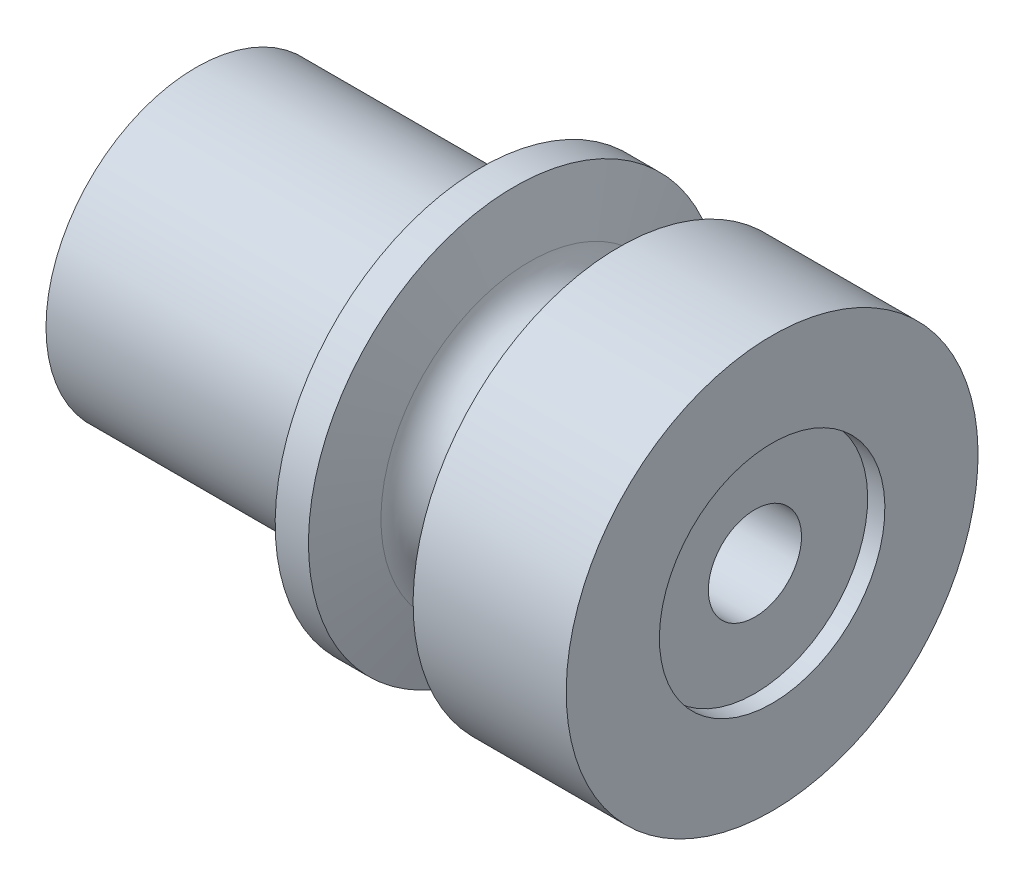
from build123d import *


with BuildPart() as part:
    # Sketch1 → Revolve1 (revolve)
    with BuildSketch(Plane.XY):
        with BuildLine():
            Line((-7.83533025, 7.706480957), (-7.041793614, 10.668))
            Line((-7.041793614, 10.668), (0.892, 10.668))
            Line((0.892, 10.668), (0.892, 5.842))
            Line((0.892, 5.842), (0, 5.842))
            Line((0, 5.842), (0, 2.413))
            Line((0, 2.413), (-24.6126, 2.413))
            Line((-24.6126, 2.413), (-28.956, 6.7564))
            Line((-28.956, 6.7564), (-28.956, 7.7724))
            Line((-28.956, 7.7724), (-14.188119198, 7.7724))
            Line((-14.188119198, 7.7724), (-14.188119198, 10.668))
            Line((-14.188119198, 10.668), (-12.462385009, 10.668))
            Line((-12.462385009, 10.668), (-11.668848373, 7.706480957))
            ThreePointArc((-11.668848373, 7.706480957), (-9.752089311, 6.2357), (-7.83533025, 7.706480957))
        make_face()
    revolve(axis=Axis((-22.598839253, 0, 0), (1, 0, 0)))


solid = part.part
